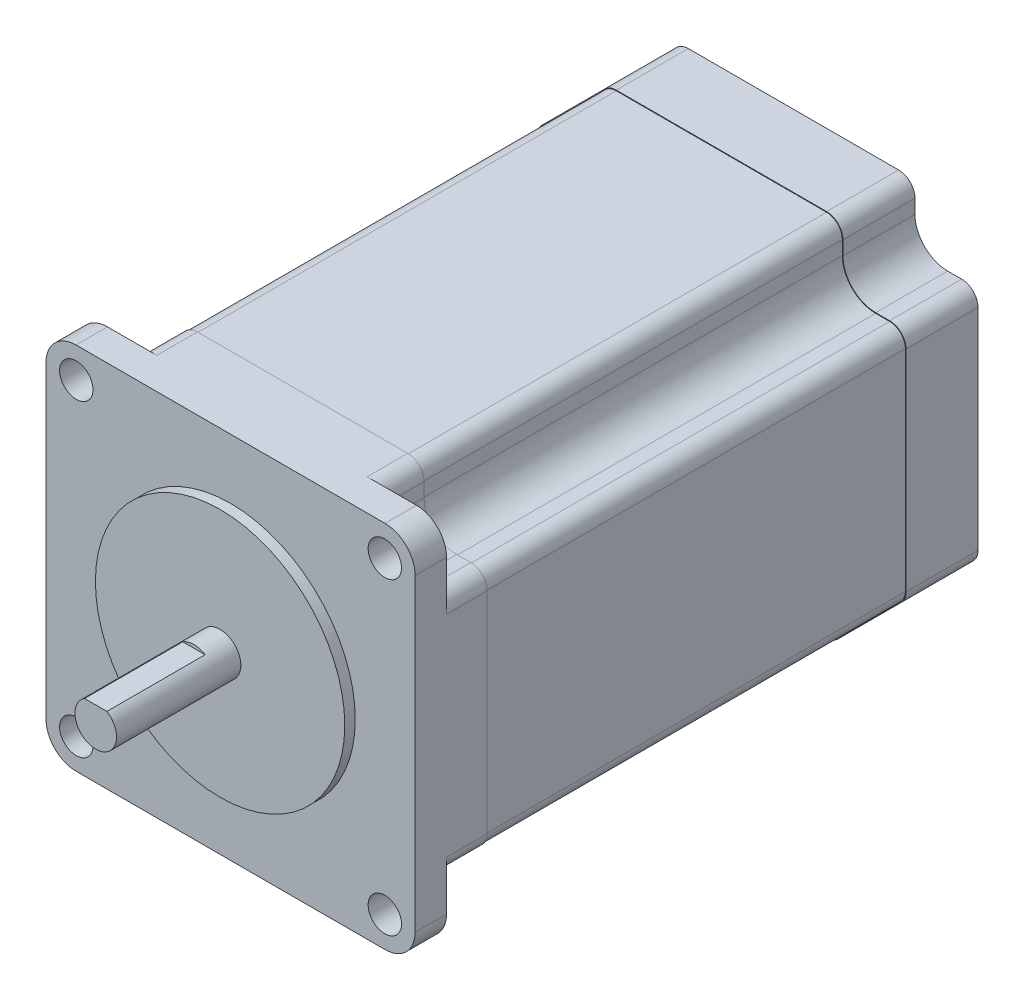
from build123d import *

# Parameters (mm, degrees)
SKETCH1_R           = 3.175
BOSS_EXTRUDE1_DEPTH = 20.6
SKETCH2_R           = 19.05
BOSS_EXTRUDE2_DEPTH = 1.6
BOSS_EXTRUDE3_DEPTH = 4.8
BOSS_EXTRUDE4_DEPTH = 81.2
SKETCH7_W           = 3.420526276
SKETCH7_H           = 1.112659396
CUT_EXTRUDE5_DEPTH  = 15
CUT_EXTRUDE6_REACH  = 88
SKETCH8_R           = 2.55
CUT_EXTRUDE7_DEPTH  = 32


with BuildPart() as part:
    # Sketch1 → Boss-Extrude1 (new body)
    with BuildSketch(Plane.XY):
        Circle(SKETCH1_R)
    extrude(amount=BOSS_EXTRUDE1_DEPTH)

    # Sketch2 → Boss-Extrude2 (add)
    with BuildSketch(Plane(origin=(0, 0, 0), x_dir=(-1, 0, 0), z_dir=(0, 0, -1))):
        Circle(SKETCH2_R)
    extrude(amount=-BOSS_EXTRUDE2_DEPTH)

    # Sketch3 → Boss-Extrude3 (add)
    with BuildSketch(Plane(origin=(0, 0, 0), x_dir=(-1, 0, 0), z_dir=(0, 0, -1))):
        with BuildLine():
            Line((23.6, -28.2), (-23.6, -28.2))
            ThreePointArc((-23.6, -28.2), (-26.852691193, -26.852691193), (-28.2, -23.6))
            Line((-28.2, -23.6), (-28.2, 23.6))
            ThreePointArc((-28.2, 23.6), (-26.852691193, 26.852691193), (-23.6, 28.2))
            Line((-23.6, 28.2), (23.6, 28.2))
            ThreePointArc((23.6, 28.2), (26.852691193, 26.852691193), (28.2, 23.6))
            Line((28.2, 23.6), (28.2, -23.6))
            ThreePointArc((28.2, -23.6), (26.852691193, -26.852691193), (23.6, -28.2))
        make_face()
    extrude(amount=BOSS_EXTRUDE3_DEPTH)

    # Sketch4 → Boss-Extrude4 (add)
    with BuildSketch(Plane(origin=(0, 0, -4.8), x_dir=(-1, 0, 0), z_dir=(0, 0, -1))):
        with BuildLine():
            Line((-18.57, 23.57), (-18.57, 25.7))
            ThreePointArc((-18.57, 25.7), (-17.837766953, 27.467766953), (-16.07, 28.2))
            Line((-16.07, 28.2), (16.07, 28.2))
            ThreePointArc((16.07, 28.2), (17.837766953, 27.467766953), (18.57, 25.7))
            Line((18.57, 25.7), (18.57, 23.57))
            ThreePointArc((18.57, 23.57), (20.034466094, 20.034466094), (23.57, 18.57))
            Line((23.57, 18.57), (25.7, 18.57))
            ThreePointArc((25.7, 18.57), (27.467766953, 17.837766953), (28.2, 16.07))
            Line((28.2, 16.07), (28.2, -16.07))
            ThreePointArc((28.2, -16.07), (27.467766953, -17.837766953), (25.7, -18.57))
            Line((25.7, -18.57), (23.57, -18.57))
            ThreePointArc((23.57, -18.57), (20.034466094, -20.034466094), (18.57, -23.57))
            Line((18.57, -23.57), (18.57, -25.7))
            ThreePointArc((18.57, -25.7), (17.837766953, -27.467766953), (16.07, -28.2))
            Line((16.07, -28.2), (-16.07, -28.2))
            ThreePointArc((-16.07, -28.2), (-17.837766953, -27.467766953), (-18.57, -25.7))
            Line((-18.57, -25.7), (-18.57, -23.57))
            ThreePointArc((-18.57, -23.57), (-20.034466094, -20.034466094), (-23.57, -18.57))
            Line((-23.57, -18.57), (-25.7, -18.57))
            ThreePointArc((-25.7, -18.57), (-27.467766953, -17.837766953), (-28.2, -16.07))
            Line((-28.2, -16.07), (-28.2, 16.07))
            ThreePointArc((-28.2, 16.07), (-27.467766953, 17.837766953), (-25.7, 18.57))
            Line((-25.7, 18.57), (-23.57, 18.57))
            ThreePointArc((-23.57, 18.57), (-20.034466094, 20.034466094), (-18.57, 23.57))
        make_face()
    extrude(amount=BOSS_EXTRUDE4_DEPTH)

    # Sketch7 → Cut-Extrude5 (cut)
    with BuildSketch(Plane.XY.offset(20.6)):
        with Locations((0, 3.231329698)):
            Rectangle(SKETCH7_W, SKETCH7_H)
    extrude(amount=-CUT_EXTRUDE5_DEPTH, mode=Mode.SUBTRACT)

    # Sketch8 → Cut-Extrude6 (cut, up to next)
    with BuildSketch(Plane.XY, mode=Mode.PRIVATE) as cut_extrude6_sk1:
        with Locations((-23.57, 23.57)):
            Circle(SKETCH8_R)
    cut_extrude6_tool1 = extrude(cut_extrude6_sk1.sketch, amount=-CUT_EXTRUDE6_REACH, mode=Mode.PRIVATE) & part.part
    add(cut_extrude6_tool1.solids().sort_by_distance((-23.57, 23.57, 0))[0], mode=Mode.SUBTRACT)
    # Sketch8 → Cut-Extrude6 (cut, up to next)
    with BuildSketch(Plane.XY, mode=Mode.PRIVATE) as cut_extrude6_sk2:
        with Locations((23.57, 23.57)):
            Circle(SKETCH8_R)
    cut_extrude6_tool2 = extrude(cut_extrude6_sk2.sketch, amount=-CUT_EXTRUDE6_REACH, mode=Mode.PRIVATE) & part.part
    add(cut_extrude6_tool2.solids().sort_by_distance((23.57, 23.57, 0))[0], mode=Mode.SUBTRACT)
    # Sketch8 → Cut-Extrude6 (cut, up to next)
    with BuildSketch(Plane.XY, mode=Mode.PRIVATE) as cut_extrude6_sk3:
        with Locations((23.57, -23.57)):
            Circle(SKETCH8_R)
    cut_extrude6_tool3 = extrude(cut_extrude6_sk3.sketch, amount=-CUT_EXTRUDE6_REACH, mode=Mode.PRIVATE) & part.part
    add(cut_extrude6_tool3.solids().sort_by_distance((23.57, -23.57, 0))[0], mode=Mode.SUBTRACT)
    # Sketch8 → Cut-Extrude6 (cut, up to next)
    with BuildSketch(Plane.XY, mode=Mode.PRIVATE) as cut_extrude6_sk4:
        with Locations((-23.57, -23.57)):
            Circle(SKETCH8_R)
    cut_extrude6_tool4 = extrude(cut_extrude6_sk4.sketch, amount=-CUT_EXTRUDE6_REACH, mode=Mode.PRIVATE) & part.part
    add(cut_extrude6_tool4.solids().sort_by_distance((-23.57, -23.57, 0))[0], mode=Mode.SUBTRACT)

    # Sketch9 → Cut-Extrude7 (cut, symmetric)
    with BuildSketch(Plane.XY.offset(-43)):
        with BuildLine():
            Line((18.57, 23.57), (18.57, 25.7))
            ThreePointArc((18.57, 25.7), (17.837766953, 27.467766953), (16.07, 28.2))
            Line((16.07, 28.2), (-16.07, 28.2))
            ThreePointArc((-16.07, 28.2), (-17.837766953, 27.467766953), (-18.57, 25.7))
            Line((-18.57, 25.7), (-18.57, 23.57))
            ThreePointArc((-18.57, 23.57), (-20.034466094, 20.034466094), (-23.57, 18.57))
            Line((-23.57, 18.57), (-25.7, 18.57))
            ThreePointArc((-25.7, 18.57), (-27.467766953, 17.837766953), (-28.2, 16.07))
            Line((-28.2, 16.07), (-28.2, -16.07))
            ThreePointArc((-28.2, -16.07), (-27.467766953, -17.837766953), (-25.7, -18.57))
            Line((-25.7, -18.57), (-23.57, -18.57))
            ThreePointArc((-23.57, -18.57), (-20.034466094, -20.034466094), (-18.57, -23.57))
            Line((-18.57, -23.57), (-18.57, -25.7))
            ThreePointArc((-18.57, -25.7), (-17.837766953, -27.467766953), (-16.07, -28.2))
            Line((-16.07, -28.2), (16.07, -28.2))
            ThreePointArc((16.07, -28.2), (17.837766953, -27.467766953), (18.57, -25.7))
            Line((18.57, -25.7), (18.57, -23.57))
            ThreePointArc((18.57, -23.57), (20.034466094, -20.034466094), (23.57, -18.57))
            Line((23.57, -18.57), (25.7, -18.57))
            ThreePointArc((25.7, -18.57), (27.467766953, -17.837766953), (28.2, -16.07))
            Line((28.2, -16.07), (28.2, 16.07))
            ThreePointArc((28.2, 16.07), (27.467766953, 17.837766953), (25.7, 18.57))
            Line((25.7, 18.57), (23.57, 18.57))
            ThreePointArc((23.57, 18.57), (20.034466094, 20.034466094), (18.57, 23.57))
        make_face()
        with BuildLine():
            Line((18.47, 23.57), (18.47, 25.7))
            ThreePointArc((18.47, 25.7), (17.767056275, 27.397056275), (16.07, 28.1))
            Line((16.07, 28.1), (-16.07, 28.1))
            ThreePointArc((-16.07, 28.1), (-17.767056275, 27.397056275), (-18.47, 25.7))
            Line((-18.47, 25.7), (-18.47, 23.57))
            ThreePointArc((-18.47, 23.57), (-19.963755416, 19.963755416), (-23.57, 18.47))
            Line((-23.57, 18.47), (-25.7, 18.47))
            ThreePointArc((-25.7, 18.47), (-27.397056275, 17.767056275), (-28.1, 16.07))
            Line((-28.1, 16.07), (-28.1, -16.07))
            ThreePointArc((-28.1, -16.07), (-27.397056275, -17.767056275), (-25.7, -18.47))
            Line((-25.7, -18.47), (-23.57, -18.47))
            ThreePointArc((-23.57, -18.47), (-19.963755416, -19.963755416), (-18.47, -23.57))
            Line((-18.47, -23.57), (-18.47, -25.7))
            ThreePointArc((-18.47, -25.7), (-17.767056275, -27.397056275), (-16.07, -28.1))
            Line((-16.07, -28.1), (16.07, -28.1))
            ThreePointArc((16.07, -28.1), (17.767056275, -27.397056275), (18.47, -25.7))
            Line((18.47, -25.7), (18.47, -23.57))
            ThreePointArc((18.47, -23.57), (19.963755416, -19.963755416), (23.57, -18.47))
            Line((23.57, -18.47), (25.7, -18.47))
            ThreePointArc((25.7, -18.47), (27.397056275, -17.767056275), (28.1, -16.07))
            Line((28.1, -16.07), (28.1, 16.07))
            ThreePointArc((28.1, 16.07), (27.397056275, 17.767056275), (25.7, 18.47))
            Line((25.7, 18.47), (23.57, 18.47))
            ThreePointArc((23.57, 18.47), (19.963755416, 19.963755416), (18.47, 23.57))
        make_face(mode=Mode.SUBTRACT)
    extrude(amount=CUT_EXTRUDE7_DEPTH, both=True, mode=Mode.SUBTRACT)


solid = part.part
